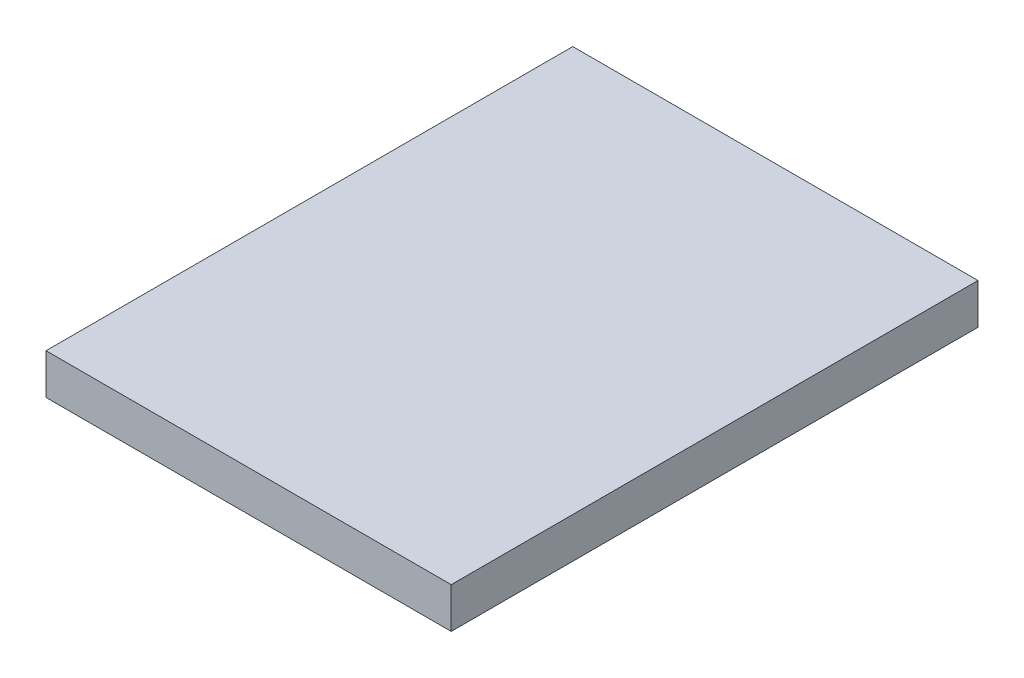
from build123d import *

# Parameters (mm, degrees)
SKETCH1_W           = 63.5
SKETCH1_H           = 82.55
BOSS_EXTRUDE1_DEPTH = 6.35


with BuildPart() as part:
    # Sketch1 → Boss-Extrude1 (new body)
    with BuildSketch(Plane(origin=(0, 0, 0), x_dir=(1, 0, 0), z_dir=(0, 1, 0))):
        with Locations((31.75, 41.275)):
            Rectangle(SKETCH1_W, SKETCH1_H)
    extrude(amount=BOSS_EXTRUDE1_DEPTH)


solid = part.part
